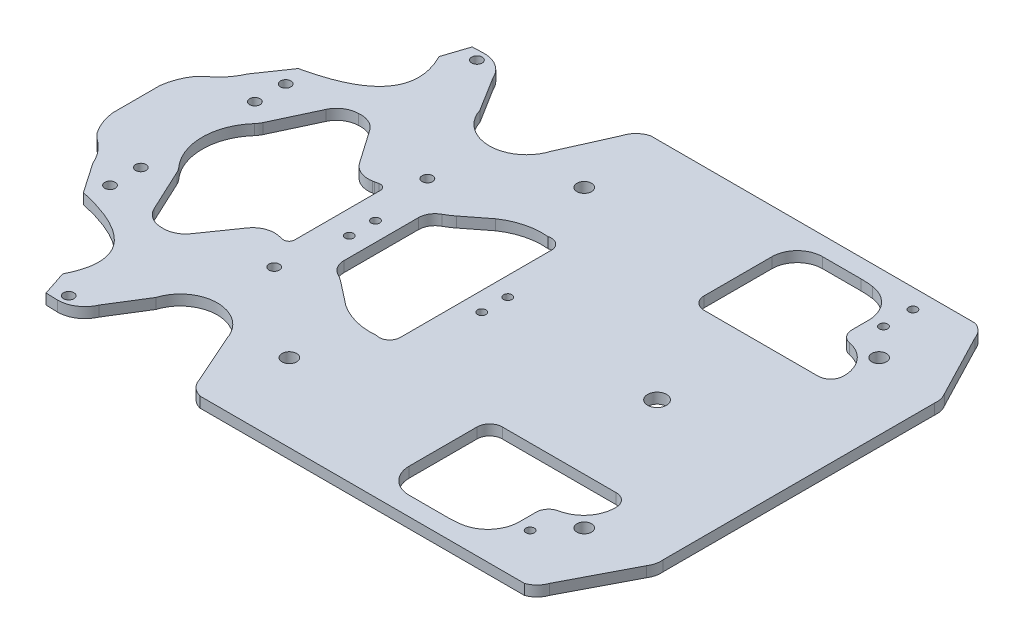
from build123d import *

# Parameters (mm, degrees)
SKETCH1_R           = 3.5
SKETCH1_R_2         = 2.5
SKETCH1_R_3         = 2
BOSS_EXTRUDE2_DEPTH = 5


with BuildPart() as part:
    # Sketch1 → Boss-Extrude2 (new body)
    with BuildSketch(Plane(origin=(0, 0, 0), x_dir=(1, 0, 0), z_dir=(0, 1, 0))):
        with BuildLine():
            Line((-131.94689332, 25.970681882), (-134.592588801, 23.324986401))
            ThreePointArc((-134.592588801, 23.324986401), (-137.58868474, 17.60266792), (-139.140311552, 11.332582281))
            Line((-139.140311552, 11.332582281), (-139.140311552, -11.332582281))
            ThreePointArc((-139.140311552, -11.332582281), (-137.58868474, -17.60266792), (-134.592588801, -23.324986401))
            Line((-134.592588801, -23.324986401), (-131.94689332, -25.970681882))
            ThreePointArc((-131.94689332, -25.970681882), (-126.689188545, -30.877876968), (-122.964643548, -37.030257619))
            Line((-122.964643548, -37.030257619), (-113.128962492, -51.346084613))
            add(Edge.make_bspline(
                [(-84.396160179, -89.98721953), (-74.548053374, -70.617720847), (-84.125654145, -57.737342542), (-113.128962492, -51.346084613)],
                knots=[0.072527255, 0.072527255, 0.072527255, 0.072527255, 1, 1, 1, 1], degree=3))
            Line((-84.396160179, -89.98721953), (-80.477300699, -101.896066655))
            Line((-80.477300699, -101.896066655), (-74.796293078, -102.076946621))
            ThreePointArc((-74.796293078, -102.076946621), (-67.604609488, -99.92775096), (-62.778823596, -94.178738404))
            Line((-62.778823596, -94.178738404), (-52.387218797, -77.500760005))
            ThreePointArc((-52.387218797, -77.500760005), (-35.405083828, -65.014987094), (-18.42294886, -77.500760005))
            Line((-18.42294886, -77.500760005), (-7.983045495, -100.927738965))
            ThreePointArc((-7.983045495, -100.927738965), (-5.375974323, -105.279578897), (-0.95323828, -107.764480662))
            Line((-0.95323828, -107.764480662), (154.12105013, -107.764480662))
            ThreePointArc((154.12105013, -107.764480662), (157.84777942, -105.444091096), (160.179787775, -101.724621245))
            Line((160.179787775, -101.724621245), (176.051157754, -71.206455594))
            ThreePointArc((176.051157754, -71.206455594), (177.340217514, -68.190997819), (177.557153354, -64.918750962))
            Line((177.557153354, -64.918750962), (177.557153354, 64.918750962))
            ThreePointArc((177.557153354, 64.918750962), (177.340217514, 68.190997819), (176.051157754, 71.206455594))
            Line((176.051157754, 71.206455594), (160.179787775, 101.724621245))
            ThreePointArc((160.179787775, 101.724621245), (157.84777942, 105.444091096), (154.12105013, 107.764480662))
            Line((154.12105013, 107.764480662), (-0.95323828, 107.764480662))
            ThreePointArc((-0.95323828, 107.764480662), (-5.375974323, 105.279578897), (-7.983045495, 100.927738965))
            Line((-7.983045495, 100.927738965), (-18.42294886, 77.500760005))
            ThreePointArc((-18.42294886, 77.500760005), (-35.405083828, 65.014987094), (-52.387218797, 77.500760005))
            Line((-52.387218797, 77.500760005), (-62.778823596, 94.178738404))
            ThreePointArc((-62.778823596, 94.178738404), (-67.604609488, 99.92775096), (-74.796293078, 102.076946621))
            Line((-74.796293078, 102.076946621), (-80.477300699, 101.896066655))
            Line((-80.477300699, 101.896066655), (-84.396160179, 89.98721953))
            add(Edge.make_bspline(
                [(-84.396160179, 89.98721953), (-74.548053374, 70.617720847), (-84.125654145, 57.737342542), (-113.128962492, 51.346084613)],
                knots=[0.072527255, 0.072527255, 0.072527255, 0.072527255, 1, 1, 1, 1], degree=3))
            Line((-113.128962492, 51.346084613), (-122.964643548, 37.030257619))
            ThreePointArc((-122.964643548, 37.030257619), (-126.689188545, 30.877876968), (-131.94689332, 25.970681882))
        make_face()
        with Locations((145.5, 70.5)):
            Circle(SKETCH1_R, mode=Mode.SUBTRACT)
        with Locations((4.5, 70.5)):
            Circle(SKETCH1_R, mode=Mode.SUBTRACT)
        with Locations((4.5, -70.5)):
            Circle(SKETCH1_R, mode=Mode.SUBTRACT)
        with Locations((145.5, -70.5)):
            Circle(SKETCH1_R, mode=Mode.SUBTRACT)
        with Locations((-73.905296724, 97.603035068)):
            Circle(SKETCH1_R_2, mode=Mode.SUBTRACT)
        with Locations((-36.642164959, 36.630202961)):
            Circle(SKETCH1_R_2, mode=Mode.SUBTRACT)
        with Locations((-36.642164959, -36.630202961)):
            Circle(SKETCH1_R_2, mode=Mode.SUBTRACT)
        with Locations((-73.905296724, -97.603035068)):
            Circle(SKETCH1_R_2, mode=Mode.SUBTRACT)
        with Locations((-109.755224174, -27.254093608)):
            Circle(SKETCH1_R_2, mode=Mode.SUBTRACT)
        with Locations((-109.755224174, -41.994093608)):
            Circle(SKETCH1_R_2, mode=Mode.SUBTRACT)
        with Locations((-109.755224174, 41.994093608)):
            Circle(SKETCH1_R_2, mode=Mode.SUBTRACT)
        with Locations((-109.755224174, 27.254093608)):
            Circle(SKETCH1_R_2, mode=Mode.SUBTRACT)
        with Locations((133.617169417, -84.482617886)):
            Circle(SKETCH1_R_3, mode=Mode.SUBTRACT)
        with Locations((133.617169417, 84.482617886)):
            Circle(SKETCH1_R_3, mode=Mode.SUBTRACT)
        with Locations((133.617169417, 98.534958019)):
            Circle(SKETCH1_R_3, mode=Mode.SUBTRACT)
        with BuildLine():
            Line((22.641562111, -35.632069218), (22.641562111, 36.652844088))
            ThreePointArc((22.641562111, 36.652844088), (20.608136604, 40.692979265), (16.151822888, 41.466787774))
            ThreePointArc((16.151822888, 41.466787774), (5.788194255, 40.650697554), (-3.683793295, 36.366744527))
            Line((-3.683793295, 36.366744527), (-14.203195163, 28.148087048))
            ThreePointArc((-14.203195163, 28.148087048), (-16.255277744, 26.678740586), (-18.42294886, 25.385982343))
            ThreePointArc((-18.42294886, 25.385982343), (-21.506931984, 22.427406429), (-22.641562111, 18.307122723))
            Line((-22.641562111, 18.307122723), (-22.641562111, -17.286347854))
            ThreePointArc((-22.641562111, -17.286347854), (-21.506931984, -21.40663156), (-18.42294886, -24.365207473))
            ThreePointArc((-18.42294886, -24.365207473), (-16.255277744, -25.657965716), (-14.203195163, -27.127312178))
            Line((-14.203195163, -27.127312178), (-3.683793295, -35.345969657))
            ThreePointArc((-3.683793295, -35.345969657), (5.788194255, -39.629922684), (16.151822888, -40.446012904))
            ThreePointArc((16.151822888, -40.446012904), (16.873563182, -40.607991845), (17.611254517, -40.662376812))
            ThreePointArc((17.611254517, -40.662376812), (21.168219128, -39.189033829), (22.641562111, -35.632069218))
        make_face(mode=Mode.SUBTRACT)
        with BuildLine():
            Line((-89.554671241, 41.117352002), (-99.147214694, 20.593394094))
            ThreePointArc((-99.147214694, 20.593394094), (-99.888375125, 19.267909053), (-100.81360523, 18.063675425))
            add(Edge.make_bspline(
                [(-100.81360523, 18.063675425), (-110.428458968, 7.271163587), (-110.428458968, -7.271012097), (-100.81360523, -18.063523935)],
                knots=[3.977868885, 3.977868885, 3.977868885, 3.977868885, 5.446909075, 5.446909075, 5.446909075, 5.446909075], degree=3, weights=[1, 0.828101657, 0.828101657, 1]))
            ThreePointArc((-100.81360523, -18.063523935), (-99.888375125, -19.267757563), (-99.147214694, -20.593242605))
            Line((-99.147214694, -20.593242605), (-89.554671241, -41.117200512))
            ThreePointArc((-89.554671241, -41.117200512), (-85.693735649, -45.513878761), (-80.075843646, -47.15))
            Line((-80.075843646, -47.15), (-78.905296724, -47.15))
            ThreePointArc((-78.905296724, -47.15), (-74.062527173, -45.961807095), (-70.319656797, -42.667093047))
            Line((-70.319656797, -42.667093047), (-59.297241663, -26.842279456))
            ThreePointArc((-59.297241663, -26.842279456), (-54.702966705, -23.150586853), (-48.842250779, -22.527718094))
            ThreePointArc((-48.842250779, -22.527718094), (-48.370274947, -22.61640832), (-47.899419977, -22.710868575))
            Line((-47.899419977, -22.710868575), (-46.142268668, -23.074578438))
            ThreePointArc((-46.142268668, -23.074578438), (-45.878558587, -23.115265356), (-45.612075542, -23.128874868))
            ThreePointArc((-45.612075542, -23.128874868), (-43.762453944, -22.362736517), (-42.996315593, -20.51311492))
            Line((-42.996315593, -20.51311492), (-42.996315593, 20.513266409))
            ThreePointArc((-42.996315593, 20.513266409), (-43.762453944, 22.362888007), (-45.612075542, 23.129026358))
            ThreePointArc((-45.612075542, 23.129026358), (-45.878558587, 23.115416846), (-46.142268668, 23.074729928))
            Line((-46.142268668, 23.074729928), (-47.899419977, 22.711020065))
            ThreePointArc((-47.899419977, 22.711020065), (-48.370274947, 22.61655981), (-48.842250779, 22.527869583))
            ThreePointArc((-48.842250779, 22.527869583), (-49.773143794, 22.401695376), (-50.711601736, 22.359523992))
            ThreePointArc((-50.711601736, 22.359523992), (-55.554371288, 23.547716898), (-59.297241663, 26.842430946))
            Line((-59.297241663, 26.842430946), (-71.047432728, 43.712107962))
            ThreePointArc((-71.047432728, 43.712107962), (-75.193394119, 46.552119459), (-80.183151299, 47.149601208))
            ThreePointArc((-80.183151299, 47.149601208), (-85.738926275, 45.485105607), (-89.554671241, 41.117352002))
        make_face(mode=Mode.SUBTRACT)
        with BuildLine():
            Line((144.587268898, 54.298841595), (144.587268898, 54.751074521))
            ThreePointArc((144.587268898, 54.751074521), (141.136808174, 64.355010875), (132.363285671, 69.567167393))
            ThreePointArc((132.363285671, 69.567167393), (128.85387667, 71.65203), (127.47369238, 75.493604542))
            Line((127.47369238, 75.493604542), (127.47369238, 83.46456071))
            ThreePointArc((127.47369238, 83.46456071), (123.732967698, 93.409858769), (114.365288749, 98.424693337))
            ThreePointArc((114.365288749, 98.424693337), (111.397974334, 98.718864685), (108.417731298, 98.8170638))
            Line((108.417731298, 98.8170638), (90.123559862, 98.8170638))
            ThreePointArc((90.123559862, 98.8170638), (81.586844795, 95.281040642), (78.050821636, 86.744325575))
            Line((78.050821636, 86.744325575), (78.050821636, 54.298841595))
            ThreePointArc((78.050821636, 54.298841595), (79.818833216, 50.030484062), (84.087190749, 48.262472483))
            Line((84.087190749, 48.262472483), (138.550899786, 48.262472483))
            ThreePointArc((138.550899786, 48.262472483), (142.819257319, 50.030484062), (144.587268898, 54.298841595))
        make_face(mode=Mode.SUBTRACT)
        with BuildLine():
            Line((84.087190749, -48.262472483), (138.550899786, -48.262472483))
            ThreePointArc((138.550899786, -48.262472483), (142.819257319, -50.030484062), (144.587268898, -54.298841595))
            Line((144.587268898, -54.298841595), (144.587268898, -54.751074521))
            ThreePointArc((144.587268898, -54.751074521), (141.136808174, -64.355010875), (132.363285671, -69.567167393))
            ThreePointArc((132.363285671, -69.567167393), (128.85387667, -71.65203), (127.47369238, -75.493604542))
            Line((127.47369238, -75.493604542), (127.47369238, -83.46456071))
            ThreePointArc((127.47369238, -83.46456071), (123.732967698, -93.409858769), (114.365288749, -98.424693337))
            ThreePointArc((114.365288749, -98.424693337), (111.397974334, -98.718864685), (108.417731298, -98.8170638))
            Line((108.417731298, -98.8170638), (90.123559862, -98.8170638))
            ThreePointArc((90.123559862, -98.8170638), (81.586844795, -95.281040642), (78.050821636, -86.744325575))
            Line((78.050821636, -86.744325575), (78.050821636, -54.298841595))
            ThreePointArc((78.050821636, -54.298841595), (79.818833216, -50.030484062), (84.087190749, -48.262472483))
        make_face(mode=Mode.SUBTRACT)
        with BuildLine():
            ThreePointArc((31.641562111, 4.798271927), (33.641562111, 6.798271927), (31.641562111, 8.798271927))
            ThreePointArc((31.641562111, 8.798271927), (29.641562111, 6.798271927), (31.641562111, 4.798271927))
        make_face(mode=Mode.SUBTRACT)
        with BuildLine():
            ThreePointArc((31.641562111, -7.681612107), (33.641562111, -5.681612107), (31.641562111, -3.681612107))
            ThreePointArc((31.641562111, -3.681612107), (29.641562111, -5.681612107), (31.641562111, -7.681612107))
        make_face(mode=Mode.SUBTRACT)
        with BuildLine():
            ThreePointArc((109.877976865, 4.478055975), (105.350700031, -0.04922086), (109.877976865, -4.576497694))
            ThreePointArc((109.877976865, -4.576497694), (114.4052537, -0.04922086), (109.877976865, 4.478055975))
        make_face(mode=Mode.SUBTRACT)
        with BuildLine():
            ThreePointArc((-31.641562111, -3.681612107), (-29.641562111, -5.681612107), (-31.641562111, -7.681612107))
            ThreePointArc((-31.641562111, -7.681612107), (-33.641562111, -5.681612107), (-31.641562111, -3.681612107))
        make_face(mode=Mode.SUBTRACT)
        with BuildLine():
            ThreePointArc((-31.641562111, 8.798271927), (-29.641562111, 6.798271927), (-31.641562111, 4.798271927))
            ThreePointArc((-31.641562111, 4.798271927), (-33.641562111, 6.798271927), (-31.641562111, 8.798271927))
        make_face(mode=Mode.SUBTRACT)
    extrude(amount=BOSS_EXTRUDE2_DEPTH)


solid = part.part
